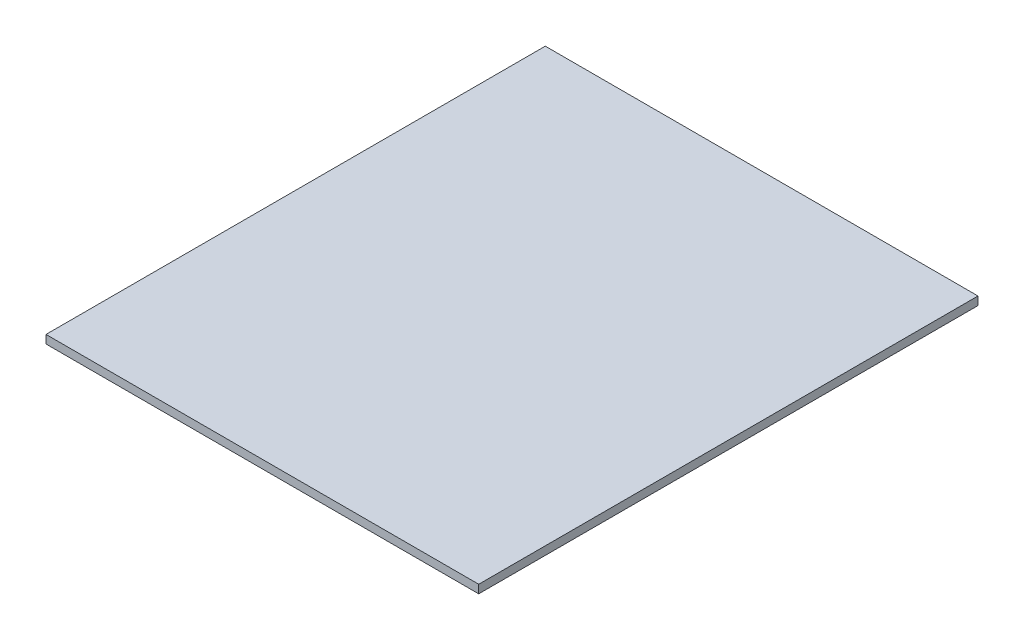
from build123d import *

# Parameters (mm, degrees)
SKETCH1_W           = 130
SKETCH1_H           = 150
BOSS_EXTRUDE1_DEPTH = 2.5


with BuildPart() as part:
    # Sketch1 → Boss-Extrude1 (new body)
    with BuildSketch(Plane(origin=(0, 0, 0), x_dir=(1, 0, 0), z_dir=(0, 1, 0))):
        Rectangle(SKETCH1_W, SKETCH1_H)
    extrude(amount=BOSS_EXTRUDE1_DEPTH)


solid = part.part
